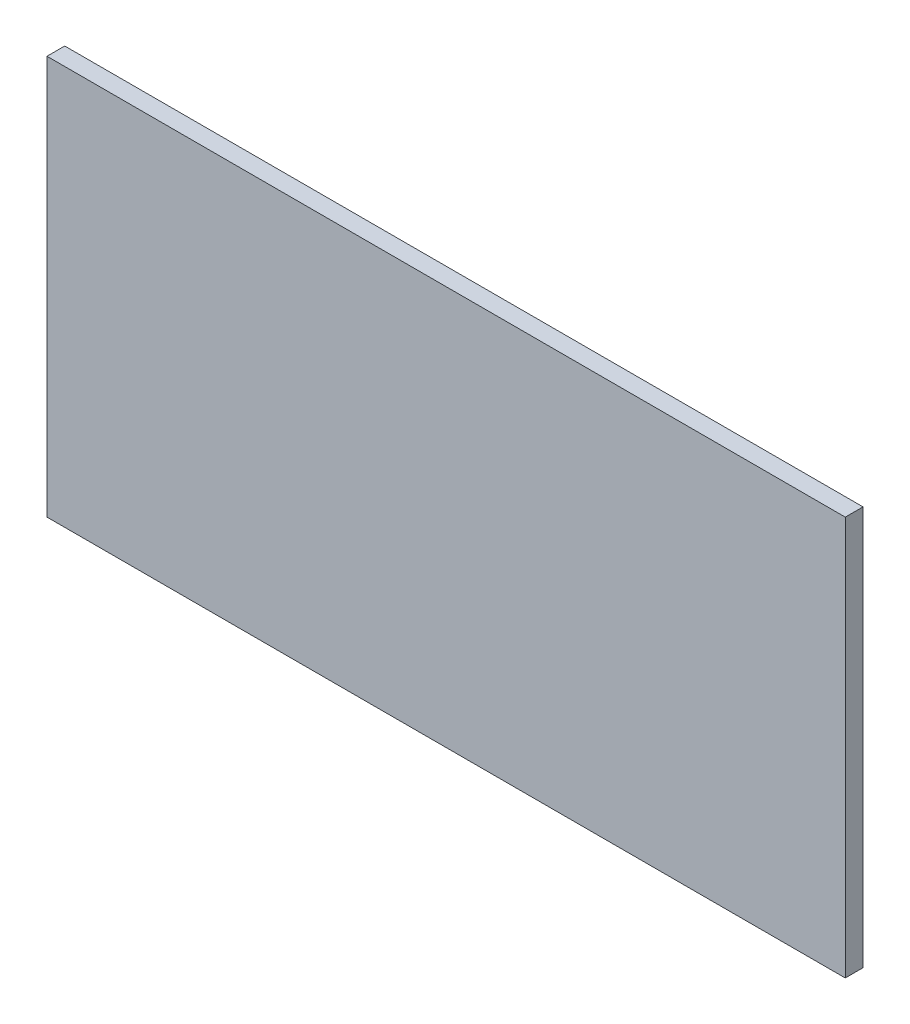
from build123d import *

# Parameters (mm, degrees)
CROQUIS1_W              = 900
CROQUIS1_H              = 450
SALIENTE_EXTRUIR1_DEPTH = 20


with BuildPart() as part:
    # Croquis1 → Saliente-Extruir1 (new body)
    with BuildSketch(Plane.XY):
        with Locations((-110.259550889, 66.968503937)):
            Rectangle(CROQUIS1_W, CROQUIS1_H)
    extrude(amount=SALIENTE_EXTRUIR1_DEPTH)


solid = part.part
